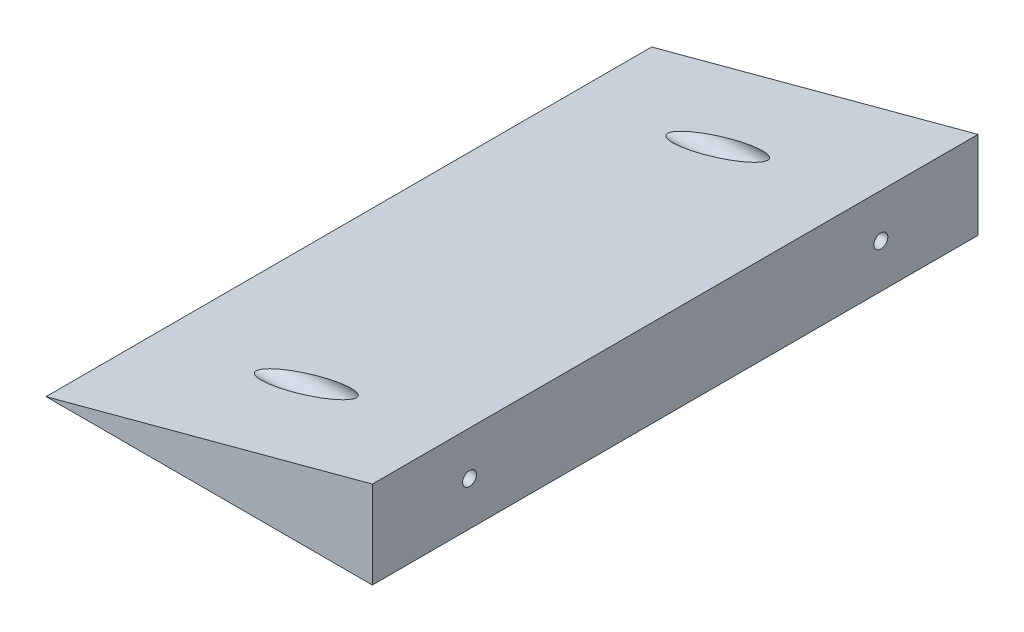
from build123d import *

# Parameters (mm, degrees)
RESSALTO_EXTRUS_O1_DEPTH = 187
ESBO_O6_R                = 2.15
CORTE_EXTRUS_O1_DEPTH    = 101.765371804
ESBO_O8_R                = 4.15
CORTE_EXTRUS_O2_DEPTH    = 75


with BuildPart() as part:
    # Esboço1 → Ressalto-extrusão1 (new body)
    with BuildSketch(Plane.XY):
        Polygon((0, 0), (0, 27), (-100.765371804, 0), align=None)
    extrude(amount=RESSALTO_EXTRUS_O1_DEPTH)

    # Esboço6 → Corte-extrusão1 (cut, through all)
    with BuildSketch(Plane(origin=(0, 0, 0), x_dir=(0, 0, -1), z_dir=(1, 0, 0))):
        with Locations((-30, 13.5)):
            Circle(ESBO_O6_R)
        with Locations((-157, 13.5)):
            Circle(ESBO_O6_R)
    extrude(amount=-CORTE_EXTRUS_O1_DEPTH, mode=Mode.SUBTRACT)

    # Esboço8 → Corte-extrusão2 (cut)
    with BuildSketch(Plane(origin=(-100, 0, 0), x_dir=(0, 0, -1), z_dir=(1, 0, 0))):
        with Locations((-30, 13.5)):
            Circle(ESBO_O8_R)
        with Locations((-157, 13.5)):
            Circle(ESBO_O8_R)
    extrude(amount=CORTE_EXTRUS_O2_DEPTH, mode=Mode.SUBTRACT)


solid = part.part
